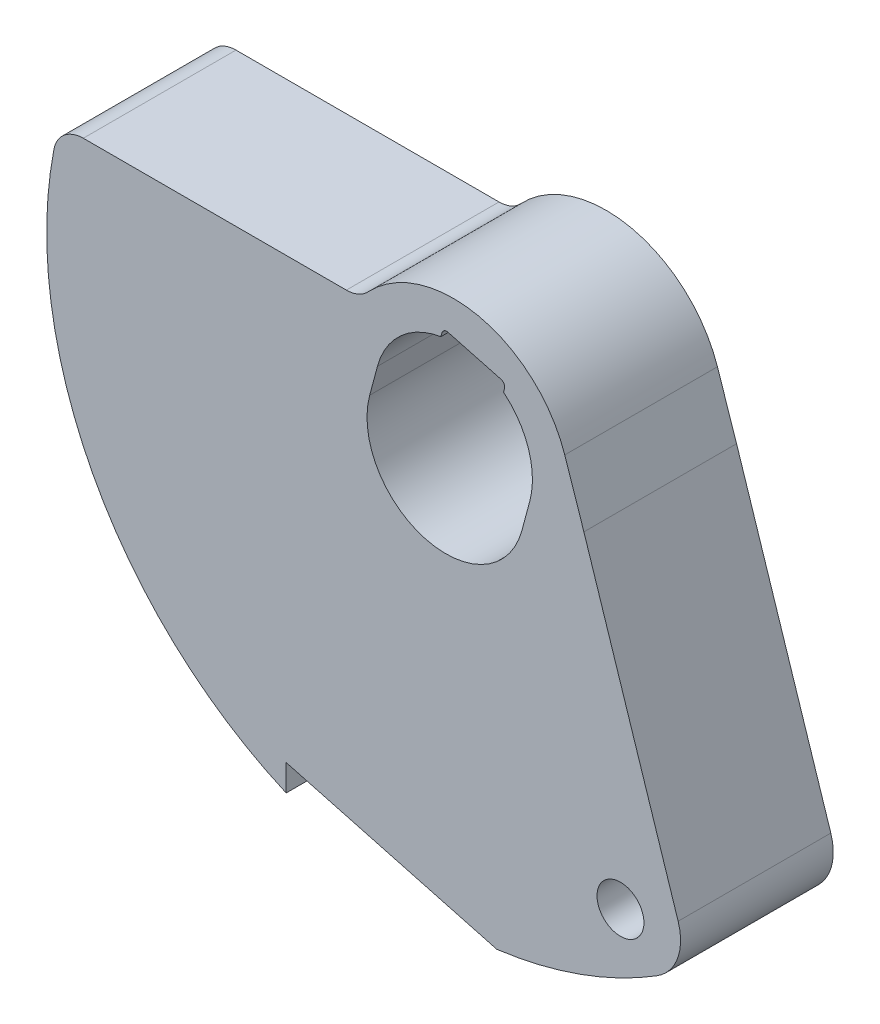
from build123d import *

# Parameters (mm, degrees)
SKETCH1_R               = 1.1938
BOSS_EXTRUDE1_DEPTH     = 7.7724
CUT_EXTRUDE1_DEPTH      = 1
CUT_EXTRUDE1_DEPTH_BACK = 8.7724
FILLET1_R               = 2.54


with BuildPart() as part:
    # Sketch1 → Boss-Extrude1 (new body)
    with BuildSketch(Plane.XY):
        with BuildLine():
            Line((-5.065262452, 5.08), (-18.456556559, 5.08))
            ThreePointArc((-18.456556559, 5.08), (-19.426909517, 4.731155792), (-19.953034117, 3.844324324))
            ThreePointArc((-19.953034117, 3.844324324), (-17.981598542, -9.463853015), (-8.128, -18.623587624))
            Line((-8.128, -18.623587624), (-8.128, -17.281160051))
            Line((-8.128, -17.281160051), (2.593084415, -20.153865962))
            ThreePointArc((2.593084415, -20.153865962), (10.900004065, -17.149119843), (17.146958643, -10.903403565))
            Line((17.146958643, -10.903403565), (12.940315476, -3.61728387))
            ThreePointArc((12.940315476, -3.61728387), (12.796393961, -3.475289825), (12.60008731, -3.426922378))
            ThreePointArc((12.60008731, -3.426922378), (9.17217903, -2.398369889), (7.028137334, 0.467212181))
            Line((7.028137334, 0.467212181), (6.053096787, 3.371693793))
            ThreePointArc((6.053096787, 3.371693793), (1.669604011, 7.303273092), (-3.95481445, 5.560217822))
            ThreePointArc((-3.95481445, 5.560217822), (-4.460344292, 5.205196933), (-5.065262452, 5.08))
        make_face()
        with Locations((8.89, -15.24)):
            Circle(SKETCH1_R, mode=Mode.SUBTRACT)
        with BuildLine():
            Line((-3.876453526, 1.038692592), (-3.482013301, 2.510763551))
            ThreePointArc((-3.482013301, 2.510763551), (-2.298514325, 4.447599489), (-0.253578298, 5.432607064))
            Line((-0.253578298, 5.432607064), (-0.201054745, 5.628627633))
            ThreePointArc((-0.201054745, 5.628627633), (-0.082709585, 5.782858048), (0.110030452, 5.808232755))
            Line((0.110030452, 5.808232755), (2.808827211, 5.085092343))
            ThreePointArc((2.808827211, 5.085092343), (2.963057626, 4.966747183), (2.988432333, 4.774007146))
            Line((2.988432333, 4.774007146), (2.93590878, 4.577986577))
            ThreePointArc((2.93590878, 4.577986577), (4.214371541, 2.702476981), (4.270893751, 0.433378367))
            Line((4.270893751, 0.433378367), (3.876453526, -1.038692592))
            ThreePointArc((3.876453526, -1.038692592), (-1.038692592, -3.876453526), (-3.876453526, 1.038692592))
        make_face(mode=Mode.SUBTRACT)
    extrude(amount=-BOSS_EXTRUDE1_DEPTH)

    # Sketch2 → Cut-Extrude1 (cut, two sides)
    with BuildSketch(Plane.XY) as cut_extrude1_sk:
        Polygon((-20.975210343, 86.652654313), (7.028137334, 0.467212181), (12.408372181, -16.091448034), (40.411719858, -102.276890166), (212.782604123, -46.270194811), (151.395673921, 142.659349668), align=None)
    extrude(amount=CUT_EXTRUDE1_DEPTH, mode=Mode.SUBTRACT)
    extrude(cut_extrude1_sk.sketch, amount=-CUT_EXTRUDE1_DEPTH_BACK, mode=Mode.SUBTRACT)

    # Fillet1
    fillet1_edges = [part.edges().sort_by_distance(p)[0] for p in [
        (12.408372181, -16.091448034, -3.8862),
    ]]
    fillet(fillet1_edges, radius=FILLET1_R)


solid = part.part
